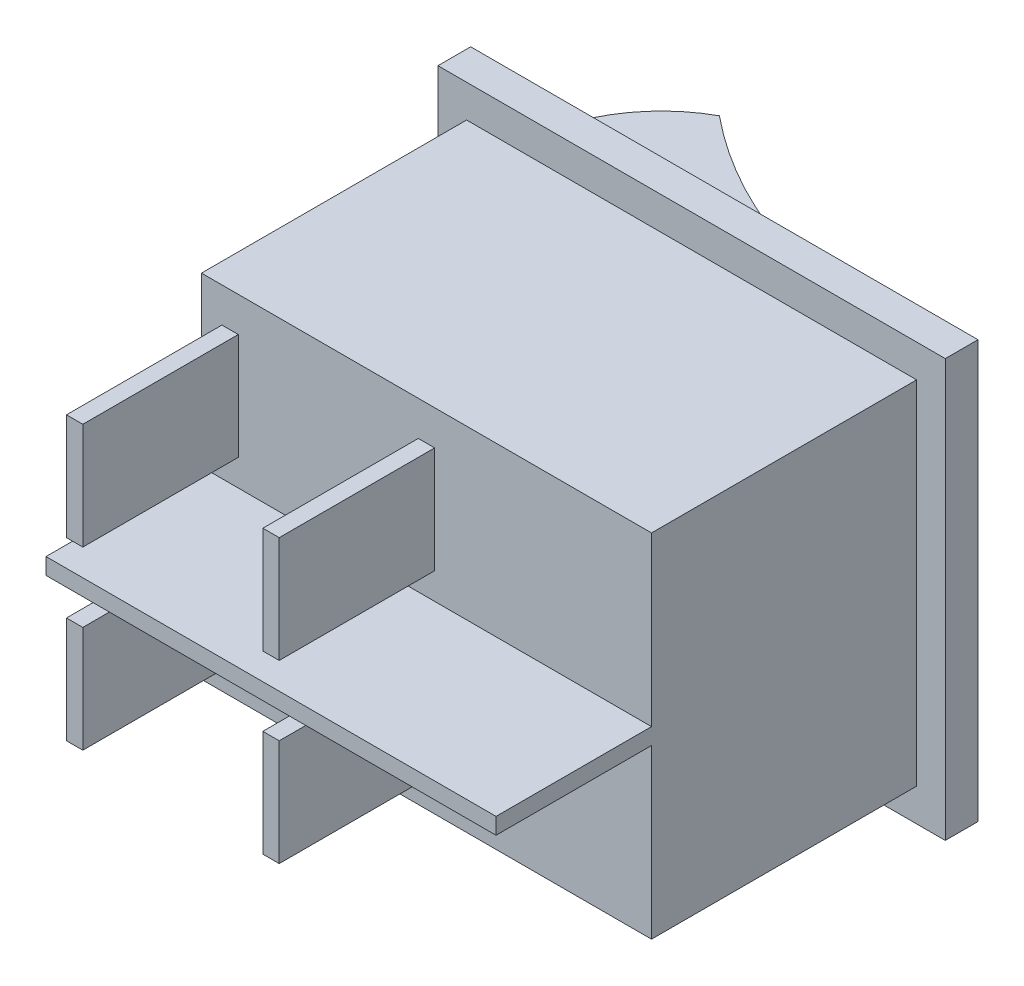
from build123d import *

# Parameters (mm, degrees)
ESBO_O1_W                = 31
ESBO_O1_H                = 25.5
RESSALTO_EXTRUS_O1_DEPTH = 2
ESBO_O2_W                = 27.5
ESBO_O2_H                = 21.5
RESSALTO_EXTRUS_O2_DEPTH = 16.2
ESBO_O3_W                = 1
ESBO_O3_H                = 6.5
ESBO_O3_W_2              = 27.5
ESBO_O3_H_2              = 1
RESSALTO_EXTRUS_O3_DEPTH = 9.5
ESBO_O4_W                = 24
ESBO_O4_H                = 19
RESSALTO_EXTRUS_O4_DEPTH = 1
RESSALTO_EXTRUS_O5_DEPTH = 19


with BuildPart() as part:
    # Esboço1 → Ressalto-extrusão1 (new body)
    with BuildSketch(Plane.XY):
        Rectangle(ESBO_O1_W, ESBO_O1_H)
    extrude(amount=RESSALTO_EXTRUS_O1_DEPTH)

    # Esboço2 → Ressalto-extrusão2 (add)
    with BuildSketch(Plane.XY.offset(2)):
        Rectangle(ESBO_O2_W, ESBO_O2_H)
    extrude(amount=RESSALTO_EXTRUS_O2_DEPTH)

    # Esboço3 → Ressalto-extrusão3 (add)
    with BuildSketch(Plane.XY.offset(18.2)):
        with Locations((-12, 5.375)):
            Rectangle(ESBO_O3_W, ESBO_O3_H)
        with Locations((0, -5.375)):
            Rectangle(ESBO_O3_W, ESBO_O3_H)
        with Locations((0, 5.375)):
            Rectangle(ESBO_O3_W, ESBO_O3_H)
        with Locations((-12, -5.375)):
            Rectangle(ESBO_O3_W, ESBO_O3_H)
        Rectangle(ESBO_O3_W_2, ESBO_O3_H_2)
    extrude(amount=RESSALTO_EXTRUS_O3_DEPTH)

    # Esboço4 → Ressalto-extrusão4 (add)
    with BuildSketch(Plane(origin=(0, 0, 0), x_dir=(-1, 0, 0), z_dir=(0, 0, -1))):
        Rectangle(ESBO_O4_W, ESBO_O4_H)
    extrude(amount=RESSALTO_EXTRUS_O4_DEPTH)

    # Esboço5 → Ressalto-extrusão5 (add)
    with BuildSketch(Plane.XZ.offset(9.5)):
        with BuildLine():
            Line((8.024552065, -1), (-12, -1))
            ThreePointArc((-12, -1), (-10.442623617, -4.60271069), (-7.5, -7.2))
            ThreePointArc((-7.5, -7.2), (-0.218681889, -2.895700597), (8.024552065, -1))
        make_face()
    extrude(amount=-RESSALTO_EXTRUS_O5_DEPTH)


solid = part.part
